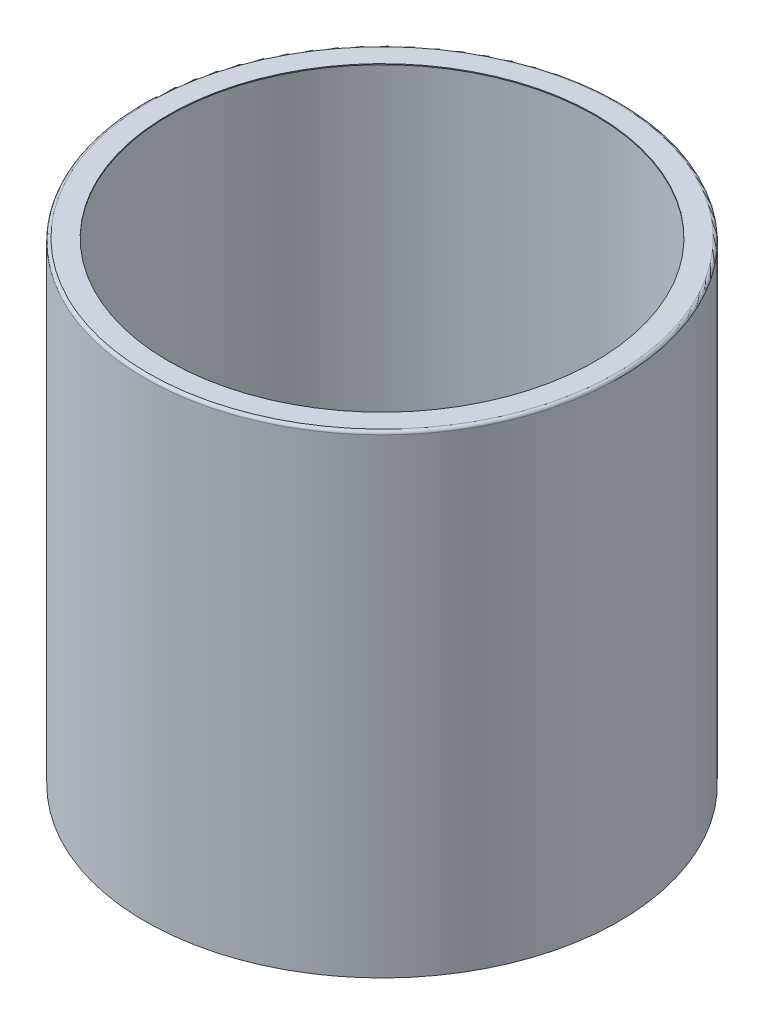
from build123d import *


with BuildPart() as part:
    # Sketch8 → Revolve1 (revolve)
    with BuildSketch(Plane(origin=(0, 0, 0), x_dir=(0, 0, -1), z_dir=(1, 0, 0))):
        with BuildLine():
            Line((254, 0), (254, -254))
            Line((254, -254), (255.0287, -254))
            Line((255.0287, -254), (255.0287, 251.8537))
            ThreePointArc((255.0287, 251.8537), (254.09876403, 254.09876403), (251.8537, 255.0287))
            Line((251.8537, 255.0287), (229.6287, 255.0287))
            Line((229.6287, 255.0287), (229.6287, 254))
            Line((229.6287, 254), (250.825, 254))
            ThreePointArc((250.825, 254), (253.07006403, 253.07006403), (254, 250.825))
            Line((254, 250.825), (254, 0))
        make_face()
    revolve(axis=Axis((0, 0, 0), (0, 1, 0)))


solid = part.part
